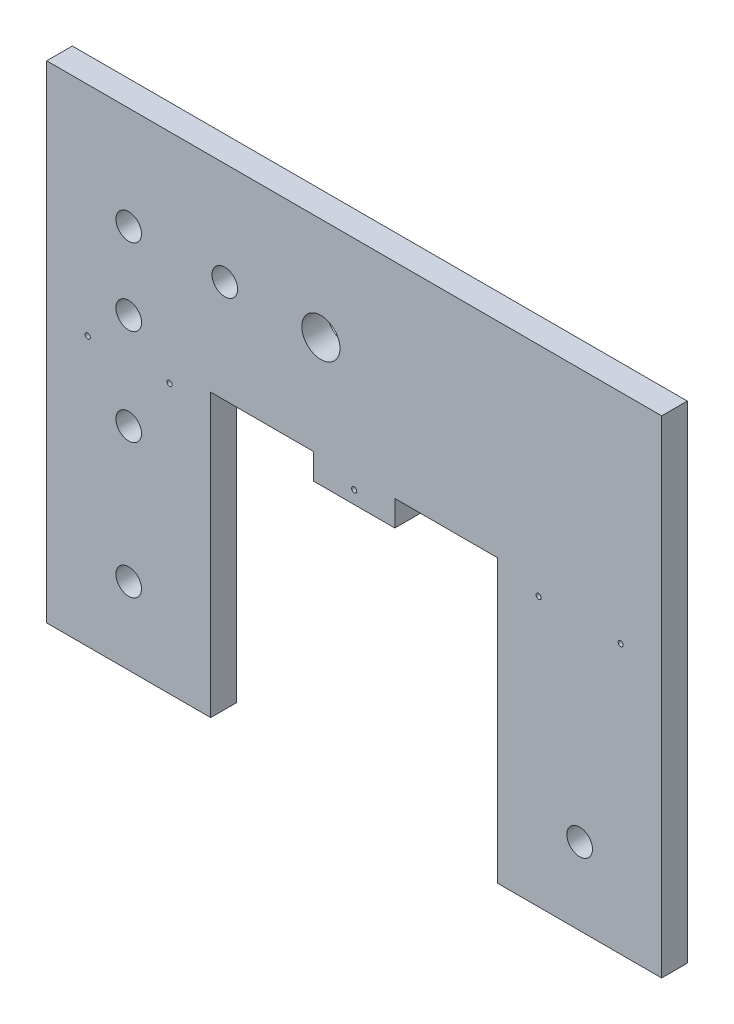
from build123d import *

# Parameters (mm, degrees)
SKETCH1_R           = 3.175
SKETCH1_R_2         = 4.7371
BOSS_EXTRUDE1_DEPTH = 6.35
SKETCH2_W           = 25.498289586
SKETCH2_H           = 6.35
CUT_EXTRUDE1_DEPTH  = 6.35
SKETCH4_R           = 0.635
CUT_EXTRUDE3_DEPTH  = 6.35
SKETCH6_R           = 0.635
CUT_EXTRUDE4_DEPTH  = 6.35


with BuildPart() as part:
    # Sketch1 → Boss-Extrude1 (new body)
    with BuildSketch(Plane.XY):
        Polygon((0, 0), (40.64, 0), (40.64, 63.5), (111.76, 63.5), (111.76, 0), (152.4, 0), (152.4, 69.85), (152.4, 120.65), (111.76, 120.65), (40.64, 120.65), (0, 120.65), (0, 69.85), align=None)
        with Locations((20.32, 95.25)):
            Circle(SKETCH1_R, mode=Mode.SUBTRACT)
        with Locations((67.945, 95.25)):
            Circle(SKETCH1_R_2, mode=Mode.SUBTRACT)
        with Locations((132.08, 19.05)):
            Circle(SKETCH1_R, mode=Mode.SUBTRACT)
        with Locations((20.32, 76.2)):
            Circle(SKETCH1_R, mode=Mode.SUBTRACT)
        with Locations((20.32, 52.3875)):
            Circle(SKETCH1_R, mode=Mode.SUBTRACT)
        with Locations((20.32, 19.05)):
            Circle(SKETCH1_R, mode=Mode.SUBTRACT)
        with Locations((44.1325, 95.25)):
            Circle(SKETCH1_R, mode=Mode.SUBTRACT)
    extrude(amount=BOSS_EXTRUDE1_DEPTH)

    # Sketch2 → Cut-Extrude1 (cut)
    with BuildSketch(Plane.XY.offset(6.35)):
        with Locations((53.389144793, 66.675)):
            Rectangle(SKETCH2_W, SKETCH2_H)
        with Locations((99.010855207, 66.675)):
            Rectangle(SKETCH2_W, SKETCH2_H)
    extrude(amount=-CUT_EXTRUDE1_DEPTH, mode=Mode.SUBTRACT)

    # Sketch4 → Cut-Extrude3 (cut)
    with BuildSketch(Plane.XY.offset(6.35)):
        with Locations((76.2, 66.675)):
            Circle(SKETCH4_R)
    extrude(amount=-CUT_EXTRUDE3_DEPTH, mode=Mode.SUBTRACT)

    # Sketch6 → Cut-Extrude4 (cut)
    with BuildSketch(Plane.XY.offset(6.35)):
        with Locations((10.16, 66.675)):
            Circle(SKETCH6_R)
        with Locations((30.435806054, 66.675)):
            Circle(SKETCH6_R)
        with Locations((121.92, 66.675)):
            Circle(SKETCH6_R)
        with Locations((142.24, 66.675)):
            Circle(SKETCH6_R)
    extrude(amount=-CUT_EXTRUDE4_DEPTH, mode=Mode.SUBTRACT)


solid = part.part
